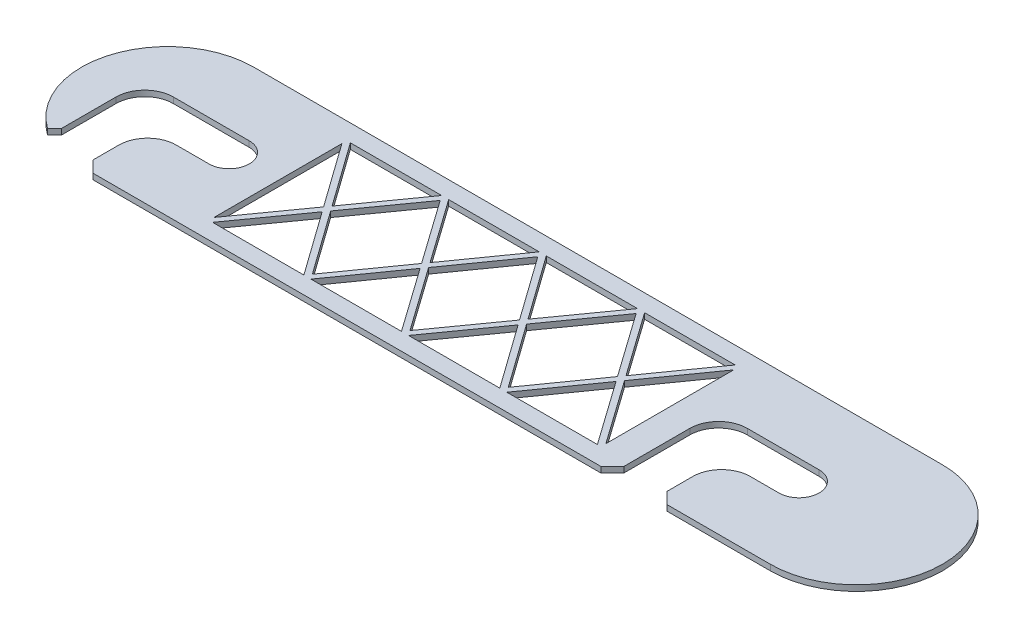
from build123d import *

# Parameters (mm, degrees)
BOSS_EXTRUDE1_DEPTH = 2
SKETCH2_W           = 68.264560608
SKETCH2_H           = 24
CUT_EXTRUDE2_DEPTH  = 1.9
RIB1_REACH          = 78.511
SKETCH4_W           = 200.105791224
SKETCH4_H           = 76.194128196
CUT_EXTRUDE3_DEPTH  = 1


with BuildPart() as part:
    # Sketch1 → Boss-Extrude1 (new body)
    with BuildSketch(Plane(origin=(0, 0, 0), x_dir=(1, 0, 0), z_dir=(0, 1, 0))):
        with BuildLine():
            Line((-60, 15), (60, 15))
            ThreePointArc((60, 15), (75, 0), (60, -15))
            Line((60, -15), (42, -15))
            Line((42, -15), (40, -13))
            Line((40, -13), (40, -8.5))
            ThreePointArc((40, -8.5), (41.464466094, -4.964466094), (45, -3.5))
            Line((45, -3.5), (50, -3.5))
            ThreePointArc((50, -3.5), (53.5, 0), (50, 3.5))
            Line((50, 3.5), (37.479805119, 3.5))
            ThreePointArc((37.479805119, 3.5), (33.944271213, 2.035533906), (32.479805119, -1.5))
            Line((32.479805119, -1.5), (32.479805119, -13))
            Line((32.479805119, -13), (30.479805119, -15))
            Line((30.479805119, -15), (-58, -15))
            Line((-58, -15), (-60, -13))
            Line((-60, -13), (-60, -8.5))
            ThreePointArc((-60, -8.5), (-58.535533906, -4.964466094), (-55, -3.5))
            Line((-55, -3.5), (-49.284755489, -3.5))
            ThreePointArc((-49.284755489, -3.5), (-45.784755489, 0), (-49.284755489, 3.5))
            Line((-49.284755489, 3.5), (-62.5, 3.5))
            ThreePointArc((-62.5, 3.5), (-66.035533906, 2.035533906), (-67.5, -1.5))
            Line((-67.5, -1.5), (-67.5, -10.990381057))
            Line((-67.5, -10.990381057), (-68.71685086, -12.207231917))
            ThreePointArc((-68.71685086, -12.207231917), (-74.284755489, 4.576653867), (-60, 15))
        make_face()
    extrude(amount=BOSS_EXTRUDE1_DEPTH)

    # Sketch2 → Cut-Extrude2 (cut)
    with BuildSketch(Plane(origin=(0, 2, 0), x_dir=(1, 0, 0), z_dir=(0, 1, 0))):
        with Locations((-6.652475185, 0)):
            Rectangle(SKETCH2_W, SKETCH2_H)
    extrude(amount=-CUT_EXTRUDE2_DEPTH, mode=Mode.SUBTRACT)

    # Sketch3 walls → Rib1 (add, up to next)
    with BuildSketch(Plane(origin=(0, 2, 0), x_dir=(1, 0, 0), z_dir=(0, 1, 0)), mode=Mode.PRIVATE) as rib1_sk1:
        Polygon((72.690772086, -74.962221531), (10.481384328, 12.862796479), (-6.650895976, -11.137203521), (-23.650895976, 12.862796479), (-86.225903046, -74.796297525), (-85.411999959, -75.377298184), (-23.654054394, 11.137203521), (-6.654054394, -12.862796479), (10.47822591, 11.137203521), (71.874747605, -75.540238871), align=None)
    rib1_tool1 = extrude(rib1_sk1.sketch, amount=-RIB1_REACH, mode=Mode.PRIVATE) - part.part
    # Sketch3 walls → Rib1 (add, up to next)
    with BuildSketch(Plane(origin=(0, 2, 0), x_dir=(1, 0, 0), z_dir=(0, 1, 0)), mode=Mode.PRIVATE) as rib1_sk2:
        Polygon((-86.225903046, 74.796297525), (-23.650895976, -12.862796479), (-6.650895976, 11.137203521), (10.481384328, -12.862796479), (72.690772086, 74.962221531), (71.874747605, 75.540238871), (10.47822591, -11.137203521), (-6.654054394, 12.862796479), (-23.654054394, -11.137203521), (-85.411999959, 75.377298184), align=None)
    rib1_tool2 = extrude(rib1_sk2.sketch, amount=-RIB1_REACH, mode=Mode.PRIVATE) - part.part
    add(rib1_tool1.solids().sort_by_distance((-15.152475185, 2, 0))[0])
    add(rib1_tool2.solids().sort_by_distance((1.913664967, 2, 0))[0])

    # Sketch4 → Cut-Extrude3 (cut)
    with BuildSketch(Plane.XZ):
        with Locations((12.775985132, -7.388521522)):
            Rectangle(SKETCH4_W, SKETCH4_H)
    extrude(amount=-CUT_EXTRUDE3_DEPTH, mode=Mode.SUBTRACT)


solid = part.part
